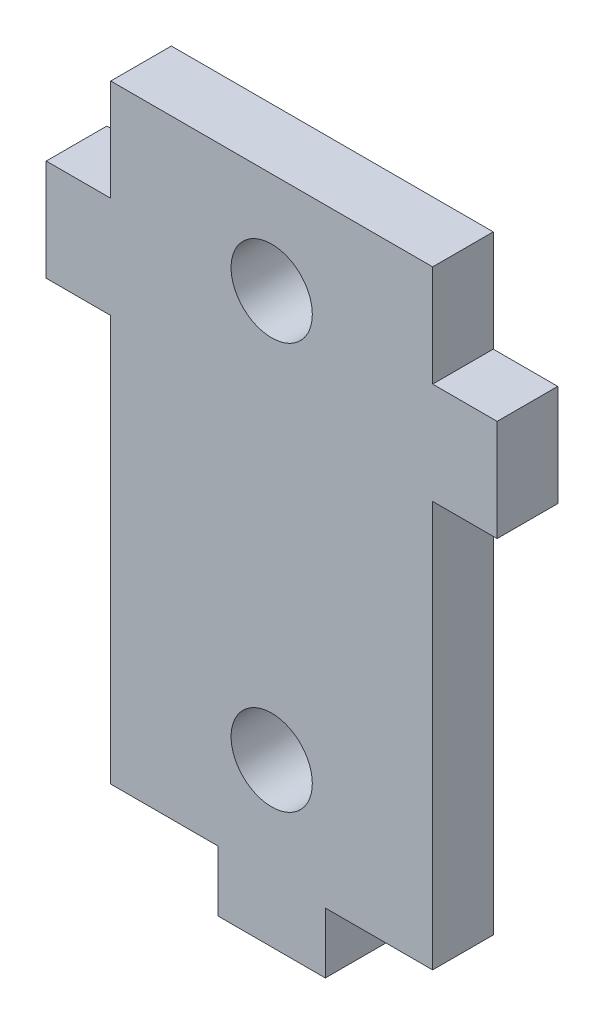
from build123d import *

# Parameters (mm, degrees)
SKETCH1_R           = 4
BOSS_EXTRUDE1_DEPTH = 5.969
SKETCH4_W           = 14.7
SKETCH4_H           = 10
BOSS_EXTRUDE4_DEPTH = 5.969
SKETCH5_W           = 8.35
SKETCH5_H           = 10
BOSS_EXTRUDE6_DEPTH = 5.969


with BuildPart() as part:
    # Sketch1 → Boss-Extrude1 (new body)
    with BuildSketch(Plane.XY):
        Polygon((-2.216666667, 18.984537882), (-2.216666667, 59.959039259), (12.783333333, 59.959039259), (12.783333333, 18.984537882), (21.133333333, 0), (10.566666667, 0), (10.566666667, -5.969), (0, -5.969), (0, 0), (-10.566666667, 0), align=None)
        with Locations((5.283333333, 49.97951963)):
            Circle(SKETCH1_R, mode=Mode.SUBTRACT)
        with Locations((5.283333333, 9.97951963)):
            Circle(SKETCH1_R, mode=Mode.SUBTRACT)
    extrude(amount=BOSS_EXTRUDE1_DEPTH)

    # Sketch4 → Boss-Extrude4 (add)
    with BuildSketch(Plane(origin=(0, 0, 0), x_dir=(-1, 0, 0), z_dir=(0, 0, -1))):
        with Locations((9.566666667, 44.959039259)):
            Rectangle(SKETCH4_W, SKETCH4_H)
        with Locations((-20.133333333, 44.959039259)):
            Rectangle(SKETCH4_W, SKETCH4_H)
    extrude(amount=-BOSS_EXTRUDE4_DEPTH)

    # Sketch5 → Boss-Extrude6 (add)
    with BuildSketch(Plane.XY.offset(5.969)):
        with Locations((16.958333333, 54.959039259)):
            Rectangle(SKETCH5_W, SKETCH5_H)
        Polygon((12.783333333, 18.984537882), (21.133333333, 0), (21.133333333, 39.959039259), (12.783333333, 39.959039259), align=None)
        Polygon((-10.566666667, 39.959039259), (-10.566666667, 0), (-2.216666667, 18.984537882), (-2.216666667, 39.959039259), align=None)
        with Locations((-6.391666667, 54.959039259)):
            Rectangle(SKETCH5_W, SKETCH5_H)
    extrude(amount=-BOSS_EXTRUDE6_DEPTH)


solid = part.part
